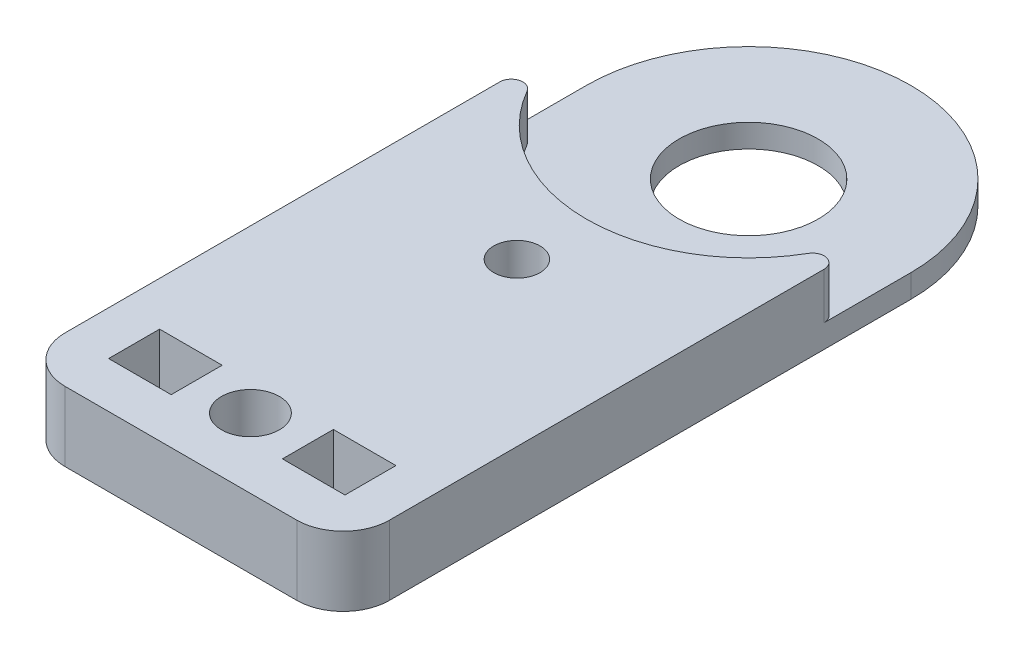
from build123d import *

# Parameters (mm, degrees)
EXTRUDE_2_DEPTH = 1
SKETCH_1_4_W    = 2.7
SKETCH_1_4_H    = 2.2
SKETCH_1_4_R    = 1.25
EXTRUDE_3_DEPTH = 3
FILLET_1_R      = 0.5
FILLET_2_R      = 2


with BuildPart() as part:
    # 草图1 → 凸台-拉伸2 (new body)
    with BuildSketch(Plane(origin=(0, 0, 0), x_dir=(1, 0, 0), z_dir=(0, 1, 0))):
        with BuildLine():
            ThreePointArc((-3, 12.25), (0, 15.25), (3, 12.25))
            Line((3, 12.25), (7, 12.25))
            ThreePointArc((7, 12.25), (0, 19.25), (-7, 12.25))
            Line((-7, 12.25), (-3, 12.25))
        make_face()
        with BuildLine():
            ThreePointArc((3, 12.25), (2.121320344, 10.128679656), (0, 9.25))
            Line((0, 9.25), (0, 5.25))
            ThreePointArc((0, 5.25), (4.949747468, 7.300252532), (7, 12.25))
            Line((7, 12.25), (3, 12.25))
        make_face()
        with BuildLine():
            Line((0, 5.25), (0, 9.25))
            ThreePointArc((0, 9.25), (-2.121320344, 10.128679656), (-3, 12.25))
            Line((-3, 12.25), (-7, 12.25))
            ThreePointArc((-7, 12.25), (-4.949747468, 7.300252532), (0, 5.25))
        make_face()
    extrude(amount=EXTRUDE_2_DEPTH)

    # 草图1<4> → 凸台-拉伸3 (add)
    with BuildSketch(Plane(origin=(0, 0, 0), x_dir=(1, 0, 0), z_dir=(0, 1, 0))):
        with BuildLine():
            ThreePointArc((7, 12.25), (4.949747468, 7.300252532), (0, 5.25))
            ThreePointArc((0, 5.25), (-4.949747468, 7.300252532), (-7, 12.25))
            Line((-7, 12.25), (-7, -12.25))
            Line((-7, -12.25), (7, -12.25))
            Line((7, -12.25), (7, 12.25))
        make_face()
        with Locations((-3.75, -9.170716156)):
            Rectangle(SKETCH_1_4_W, SKETCH_1_4_H, mode=Mode.SUBTRACT)
        with Locations((0, -9.25)):
            Circle(SKETCH_1_4_R, mode=Mode.SUBTRACT)
        with Locations((3.75, -9.170716156)):
            Rectangle(SKETCH_1_4_W, SKETCH_1_4_H, mode=Mode.SUBTRACT)
        with BuildLine():
            ThreePointArc((1, 2.25), (-0.707106781, 1.542893219), (0, 3.25))
            ThreePointArc((0, 3.25), (0.707106781, 2.957106781), (1, 2.25))
        make_face(mode=Mode.SUBTRACT)
    extrude(amount=EXTRUDE_3_DEPTH)

    # 圆角1
    fillet_1_edges = [part.edges().sort_by_distance(p)[0] for p in [
        (7, 2, -12.25),
        (-7, 2, -12.25),
    ]]
    fillet(fillet_1_edges, radius=FILLET_1_R)

    # 圆角2
    fillet_2_edges = [part.edges().sort_by_distance(p)[0] for p in [
        (7, 1.5, 12.25),
        (-7, 1.5, 12.25),
    ]]
    fillet(fillet_2_edges, radius=FILLET_2_R)


solid = part.part
